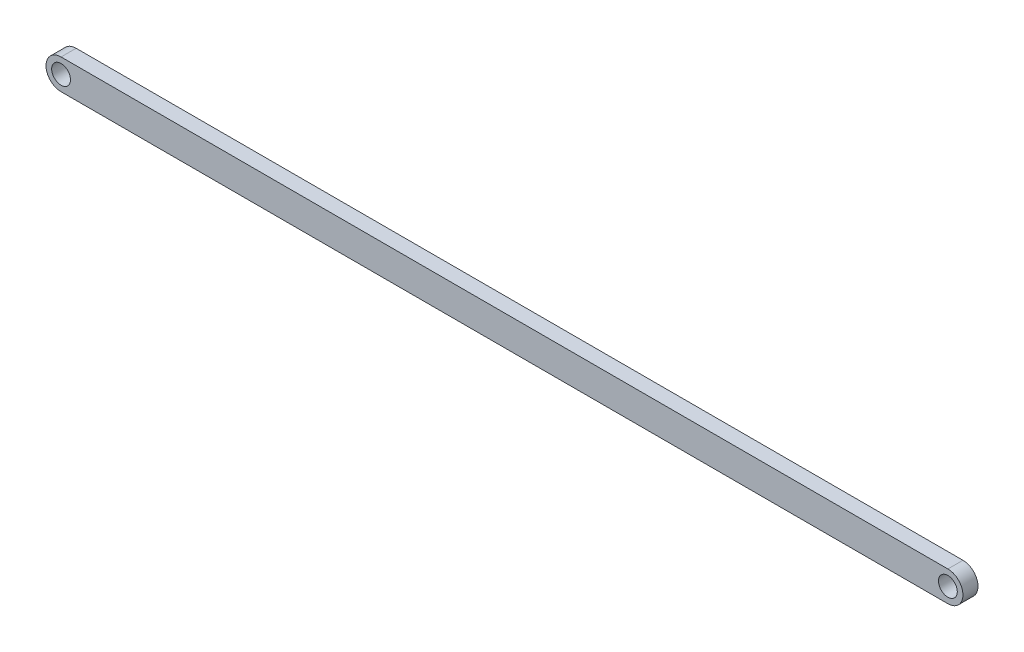
from build123d import *

# Parameters (mm, degrees)
SKETCH1_R           = 1.984375
BOSS_EXTRUDE1_DEPTH = 3.175


with BuildPart() as part:
    # Sketch1 → Boss-Extrude1 (new body)
    with BuildSketch(Plane.XY):
        with BuildLine():
            Line((0, -3.175), (186.944, -3.175))
            ThreePointArc((186.944, -3.175), (190.119, 0), (186.944, 3.175))
            Line((186.944, 3.175), (0, 3.175))
            ThreePointArc((0, 3.175), (-3.175, 0), (0, -3.175))
        make_face()
        Circle(SKETCH1_R, mode=Mode.SUBTRACT)
        with Locations((186.944, 0)):
            Circle(SKETCH1_R, mode=Mode.SUBTRACT)
    extrude(amount=BOSS_EXTRUDE1_DEPTH)


solid = part.part
